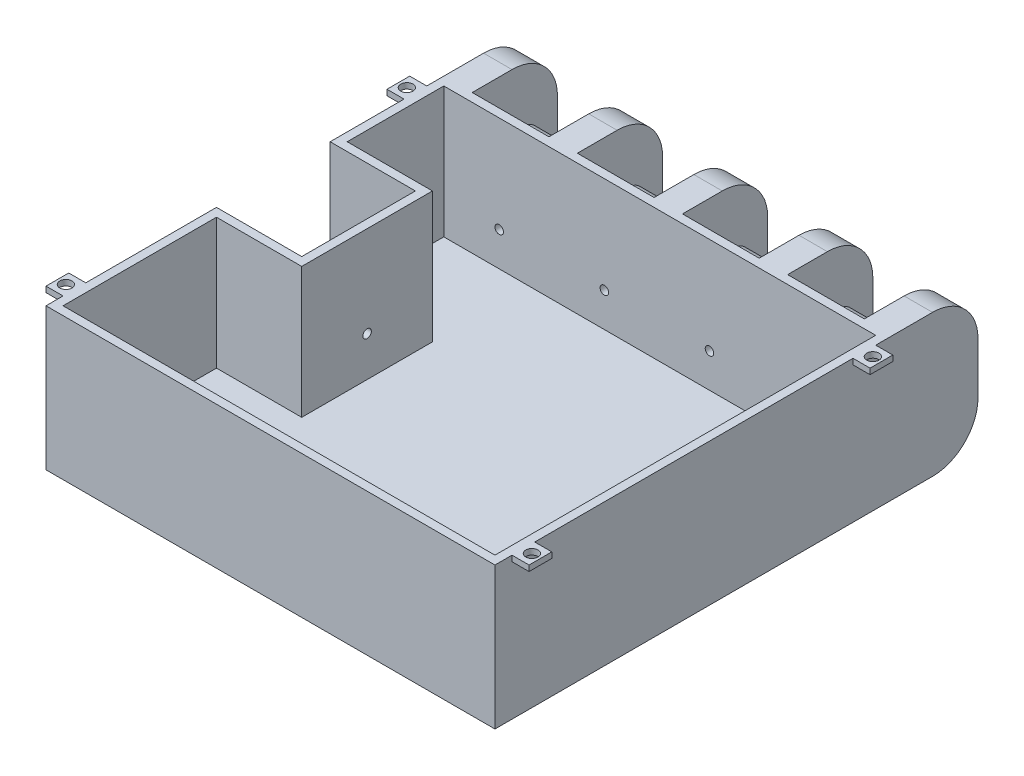
from build123d import *

# Parameters (mm, degrees)
BOSS_EXTRUDE1_DEPTH  = 25
SKETCH3_R            = 2.8
BOSS_EXTRUDE2_DEPTH  = 69
CUT_EXTRUDE2_DEPTH   = 23
SKETCH9_R            = 2.311028434
BOSS_EXTRUDE3_DEPTH  = 20
FILLET1_R            = 8
SKETCH10_R           = 0.75
CUT_EXTRUDE4_DEPTH   = 2
LPATTERN2_COUNT      = 2
LPATTERN2_PITCH      = 2
LPATTERN2_COUNT_DIR2 = 4
LPATTERN2_PITCH_DIR2 = 18.5
SKETCH11_R           = 0.75
CUT_EXTRUDE5_DEPTH   = 2
SKETCH13_W           = 4
SKETCH13_H           = 1
BOSS_EXTRUDE4_DEPTH  = 3
SKETCH14_R           = 1.078343224
CUT_EXTRUDE6_DEPTH   = 2
LPATTERN3_COUNT      = 2
LPATTERN3_PITCH      = 60
LPATTERN3_COUNT_DIR2 = 2
LPATTERN3_PITCH_DIR2 = 82
LPATTERN4_COUNT      = 2
LPATTERN4_PITCH      = 60
LPATTERN4_COUNT_DIR2 = 2
LPATTERN4_PITCH_DIR2 = 82


with BuildPart() as part:
    # Sketch2 → Boss-Extrude1 (new body)
    with BuildSketch(Plane(origin=(0, 0, 0), x_dir=(1, 0, 0), z_dir=(0, 1, 0))):
        Polygon((0, 0), (79, 0), (79, 85), (74, 85), (74, 70), (60.5, 70), (60.5, 85), (55.5, 85), (55.5, 70), (42, 70), (42, 85), (37, 85), (37, 70), (23.5, 70), (23.5, 85), (18.5, 85), (18.5, 70), (5, 70), (5, 85), (0, 85), (0, 50), (15, 50), (15, 30), (0, 30), align=None)
    extrude(amount=BOSS_EXTRUDE1_DEPTH)

    # Sketch3 → Boss-Extrude2 (add)
    with BuildSketch(Plane.ZY.offset(-74)):
        with Locations((-79, 12.5)):
            Circle(SKETCH3_R)
    extrude(amount=BOSS_EXTRUDE2_DEPTH)

    # Sketch4 → Cut-Extrude2 (cut)
    with BuildSketch(Plane(origin=(0, 25, 0), x_dir=(1, 0, 0), z_dir=(0, 1, 0))):
        Polygon((1.5, 68.5), (1.5, 51.5), (16.5, 51.5), (16.5, 28.5), (1.5, 28.5), (1.5, 1.5), (77.5, 1.5), (77.5, 68.5), align=None)
    extrude(amount=-CUT_EXTRUDE2_DEPTH, mode=Mode.SUBTRACT)

    # Sketch9 → Boss-Extrude3 (add)
    with BuildSketch(Plane.XY.offset(-50)):
        with Locations((7.5, 12.5)):
            Circle(SKETCH9_R)
    extrude(amount=BOSS_EXTRUDE3_DEPTH)

    # Fillet1
    fillet1_edges = [part.edges().sort_by_distance(p)[0] for p in [
        (76.5, 25, -85),
        (2.5, 0, -85),
        (21, 0, -85),
        (39.5, 0, -85),
        (58, 0, -85),
        (76.5, 0, -85),
        (58, 25, -85),
        (39.5, 25, -85),
        (21, 25, -85),
        (2.5, 25, -85),
    ]]
    fillet(fillet1_edges, radius=FILLET1_R)

    # Sketch10 → Cut-Extrude4 (cut)
    with BuildSketch(Plane.XY.offset(-68.5)):
        with Locations((11.25, 8)):
            Circle(SKETCH10_R)
    cut_extrude4 = extrude(amount=-CUT_EXTRUDE4_DEPTH, mode=Mode.SUBTRACT)

    # LPattern2: Cut-Extrude4 2 × 4
    with Locations(*[(j * LPATTERN2_PITCH_DIR2, 0, i * LPATTERN2_PITCH) for i in range(LPATTERN2_COUNT) for j in range(LPATTERN2_COUNT_DIR2) if (i, j) != (0, 0)]):
        add(cut_extrude4, mode=Mode.SUBTRACT)

    # Sketch11 → Cut-Extrude5 (cut)
    with BuildSketch(Plane(origin=(16.5, 0, 0), x_dir=(0, 0, -1), z_dir=(1, 0, 0))):
        with Locations((40, 9)):
            Circle(SKETCH11_R)
    extrude(amount=-CUT_EXTRUDE5_DEPTH, mode=Mode.SUBTRACT)

    # Sketch13 → Boss-Extrude4 (add)
    with BuildSketch(Plane(origin=(79, 0, 0), x_dir=(0, 0, -1), z_dir=(1, 0, 0))):
        with Locations((5, 24.5)):
            Rectangle(SKETCH13_W, SKETCH13_H)
    boss_extrude4 = extrude(amount=BOSS_EXTRUDE4_DEPTH)

    # Sketch14 → Cut-Extrude6 (cut, through all)
    with BuildSketch(Plane(origin=(0, 24, 0), x_dir=(-1, 0, 0), z_dir=(0, -1, 0))):
        with Locations((-80.5, 5)):
            Circle(SKETCH14_R)
    cut_extrude6 = extrude(amount=-CUT_EXTRUDE6_DEPTH, mode=Mode.SUBTRACT)

    # LPattern3: Boss-Extrude4 2 × 2
    with Locations(*[(-j * LPATTERN3_PITCH_DIR2, 0, -i * LPATTERN3_PITCH) for i in range(LPATTERN3_COUNT) for j in range(LPATTERN3_COUNT_DIR2) if (i, j) != (0, 0)]):
        add(boss_extrude4)

    # LPattern4: Cut-Extrude6 2 × 2
    with Locations(*[(-j * LPATTERN4_PITCH_DIR2, 0, -i * LPATTERN4_PITCH) for i in range(LPATTERN4_COUNT) for j in range(LPATTERN4_COUNT_DIR2) if (i, j) != (0, 0)]):
        add(cut_extrude6, mode=Mode.SUBTRACT)


solid = part.part
